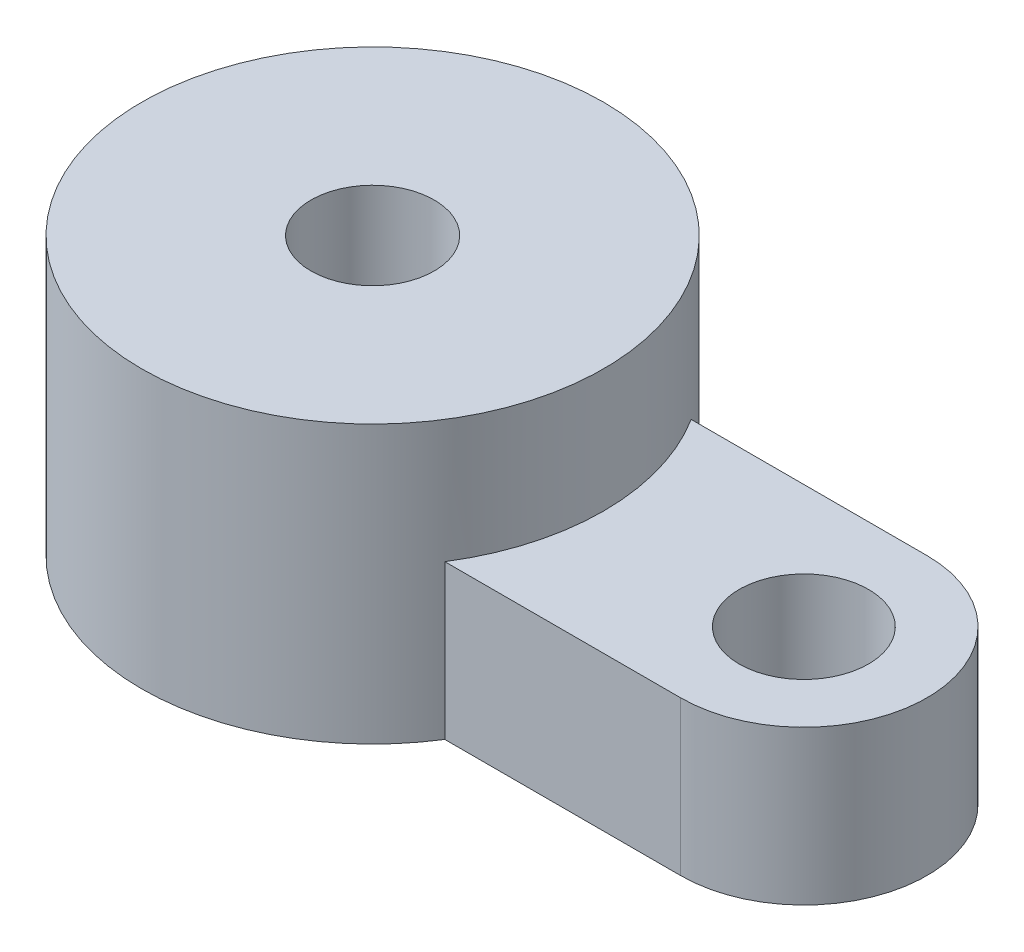
from build123d import *

# Parameters (mm, degrees)
SKETCH_1_R           = 2.1
EXTRUDE_1_DEPTH      = 5
SKETCH_2_R           = 7.5
SKETCH_2_R_2         = 2
EXTRUDE_2_DEPTH      = 4
EXTRUDE_2_DEPTH_BACK = 5
SKETCH_3_R           = 1.85
CUT_EXTRUDE_1_DEPTH  = 12


with BuildPart() as part:
    # 草图1 → 凸台-拉伸1 (new body)
    with BuildSketch(Plane(origin=(0, 0, 0), x_dir=(1, 0, 0), z_dir=(0, 1, 0))):
        with BuildLine():
            Line((0, 4), (14.003, 4))
            ThreePointArc((14.003, 4), (18.003, 0), (14.003, -4))
            Line((14.003, -4), (0, -4))
            ThreePointArc((0, -4), (-4, 0), (0, 4))
        make_face()
        Circle(SKETCH_1_R, mode=Mode.SUBTRACT)
        with Locations((14.003, 0)):
            Circle(SKETCH_1_R, mode=Mode.SUBTRACT)
    extrude(amount=EXTRUDE_1_DEPTH)

    # 草图2 → 凸台-拉伸2 (add, two sides)
    with BuildSketch(Plane(origin=(0, 5, 0), x_dir=(1, 0, 0), z_dir=(0, 1, 0))) as extrude_2_sk:
        Circle(SKETCH_2_R)
        Circle(SKETCH_2_R_2, mode=Mode.SUBTRACT)
    extrude(amount=EXTRUDE_2_DEPTH)
    extrude(extrude_2_sk.sketch, amount=-EXTRUDE_2_DEPTH_BACK)

    # 草图3 → 切除-拉伸1 (cut)
    with BuildSketch(Plane.XY):
        with Locations((0, 4.5)):
            Circle(SKETCH_3_R)
    extrude(amount=-CUT_EXTRUDE_1_DEPTH, mode=Mode.SUBTRACT)


solid = part.part
